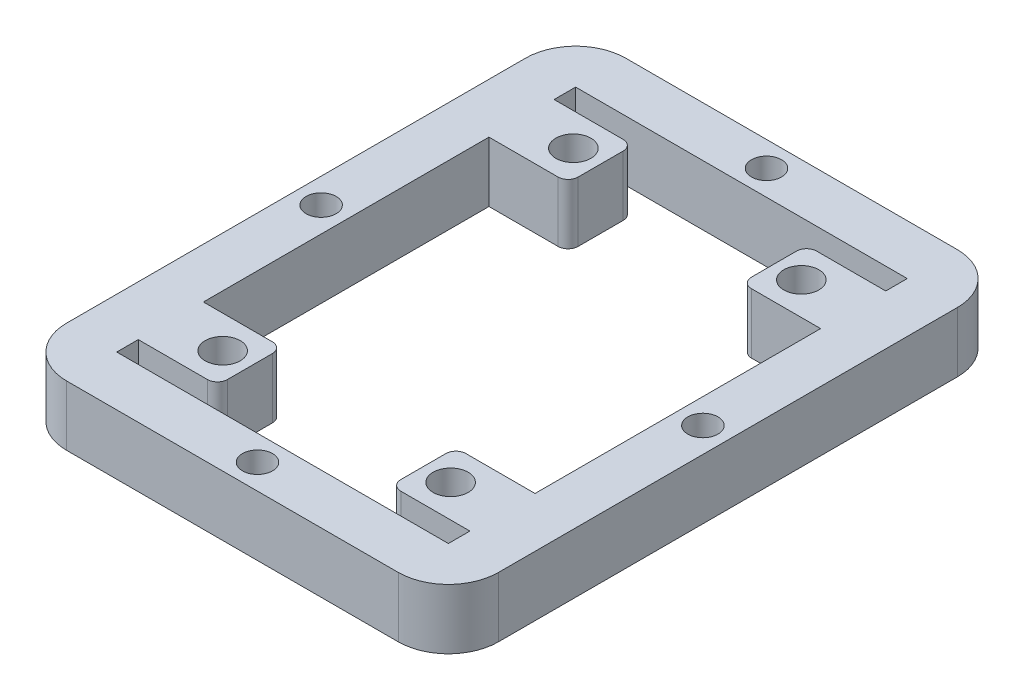
from build123d import *

# Parameters (mm, degrees)
SKETCH1_W           = 43.1
SKETCH1_H           = 55.8
SKETCH1_R           = 1.75
SKETCH1_R_2         = 1.5
BOSS_EXTRUDE1_DEPTH = 6
FILLET3_R           = 5
FILLET4_R           = 1


with BuildPart() as part:
    # Sketch1 → Boss-Extrude1 (new body)
    with BuildSketch(Plane(origin=(0, 0, 0), x_dir=(1, 0, 0), z_dir=(0, 1, 0))):
        Rectangle(SKETCH1_W, SKETCH1_H)
        with Locations((11.375, 17.5)):
            Circle(SKETCH1_R, mode=Mode.SUBTRACT)
        with Locations((11.375, -17.5)):
            Circle(SKETCH1_R, mode=Mode.SUBTRACT)
        with Locations((-11.375, -17.5)):
            Circle(SKETCH1_R, mode=Mode.SUBTRACT)
        with Locations((-11.375, 17.5)):
            Circle(SKETCH1_R, mode=Mode.SUBTRACT)
        with Locations((0, 25.4)):
            Circle(SKETCH1_R_2, mode=Mode.SUBTRACT)
        with Locations((-19.05, 0)):
            Circle(SKETCH1_R_2, mode=Mode.SUBTRACT)
        with Locations((19.05, 0)):
            Circle(SKETCH1_R_2, mode=Mode.SUBTRACT)
        with Locations((0, -25.4)):
            Circle(SKETCH1_R_2, mode=Mode.SUBTRACT)
        Polygon((14.25, -14.25), (8.65, -14.25), (8.65, -20.75), (14.25, -20.75), (16.55, -20.75), (16.55, -22.9), (-16.55, -22.9), (-16.55, -20.75), (-14.25, -20.75), (-8.65, -20.75), (-8.65, -14.25), (-14.25, -14.25), (-16.55, -14.25), (-16.55, 14.25), (-14.25, 14.25), (-8.65, 14.25), (-8.65, 20.75), (-14.25, 20.75), (-16.55, 20.75), (-16.55, 22.9), (16.55, 22.9), (16.55, 20.75), (14.25, 20.75), (8.65, 20.75), (8.65, 14.25), (14.25, 14.25), (16.55, 14.25), (16.55, -14.25), align=None, mode=Mode.SUBTRACT)
    extrude(amount=BOSS_EXTRUDE1_DEPTH)

    # Fillet3
    fillet3_edges = [part.edges().sort_by_distance(p)[0] for p in [
        (-21.55, 3, 27.9),
        (-21.55, 3, -27.9),
        (21.55, 3, -27.9),
        (21.55, 3, 27.9),
    ]]
    fillet(fillet3_edges, radius=FILLET3_R)

    # Fillet4
    fillet4_edges = [part.edges().sort_by_distance(p)[0] for p in [
        (-8.65, 3, -20.75),
        (-8.65, 3, -14.25),
        (-8.65, 3, 14.25),
        (-8.65, 3, 20.75),
        (8.65, 3, 20.75),
        (8.65, 3, 14.25),
        (8.65, 3, -14.25),
        (8.65, 3, -20.75),
    ]]
    fillet(fillet4_edges, radius=FILLET4_R)


solid = part.part
